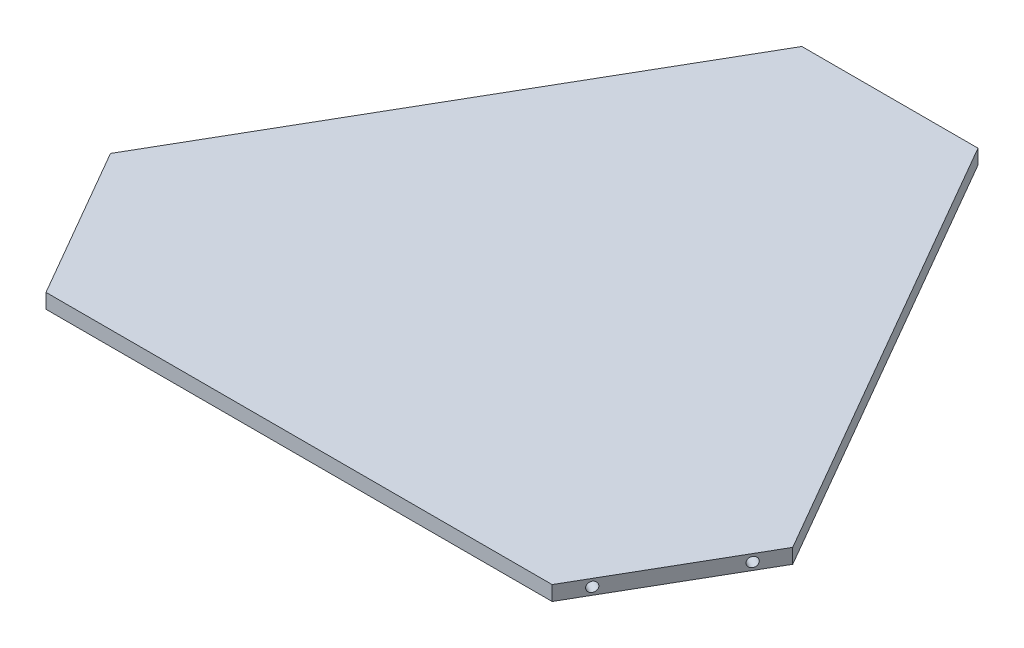
from build123d import *

# Parameters (mm, degrees)
BOSS_EXTRUDE1_DEPTH            = 6.35
M5X0_8_TAPPED_HOLE1_AT_2_COUNT = 2
M5X0_8_TAPPED_HOLE1_AT_2_PITCH = 50.8
CIRPATTERN1_COUNT              = 3


with BuildPart() as part:
    # Sketch1 → Boss-Extrude1 (new body)
    with BuildSketch(Plane(origin=(0, 0, 0), x_dir=(1, 0, 0), z_dir=(0, 1, 0))):
        Polygon((-147.591032992, -41.217632116), (-109.491032992, -107.208767884), (109.491032992, -107.208767884), (147.591032992, -41.217632116), (38.1, 148.4264), (-38.1, 148.4264), align=None)
    extrude(amount=BOSS_EXTRUDE1_DEPTH)

    # Sketch3 → M5x0.8 Tapped Hole1 (revolve, cut)
    with BuildSketch(Plane(origin=(115.841032992, 3.175, 96.210245256), x_dir=(0.5, 0, -0.866025404), z_dir=(0, 1, 0))):
        Polygon((0, 0), (0, 13.9618073), (2.1, 12.7), (2.1, 0), align=None)
    m5x0_8_tapped_hole1 = revolve(axis=Axis((121.340294306, 3.175, 99.385245256), (-0.866025404, 0, -0.5)), mode=Mode.SUBTRACT)

    # M5x0.8 Tapped Hole1 at 2: M5x0.8 Tapped Hole1 ×2
    with Locations(*[Vector(0.5, 0, -0.866025404) * (i * M5X0_8_TAPPED_HOLE1_AT_2_PITCH) for i in range(1, M5X0_8_TAPPED_HOLE1_AT_2_COUNT)]):
        add(m5x0_8_tapped_hole1, mode=Mode.SUBTRACT)

    # CirPattern1: M5x0.8 Tapped Hole1 ×3 about axis
    cirpattern1_axis = Axis((0, 6.6675, 0), (0, -1, 0))
    for i in range(1, CIRPATTERN1_COUNT):
        add(m5x0_8_tapped_hole1.rotate(cirpattern1_axis, i * 360 / CIRPATTERN1_COUNT), mode=Mode.SUBTRACT)

    # CirPattern1 copy 1 sketch → CirPattern1 copy 1 (revolve, cut)
    with BuildSketch(Plane(origin=(-115.841032992, 3.175, 96.210245256), x_dir=(0.5, 0, 0.866025404), z_dir=(0, 1, 0))):
        Polygon((0, 0), (0, 13.9618073), (2.1, 12.7), (2.1, 0), align=None)
    revolve(axis=Axis((-121.340294306, 3.175, 99.385245256), (0.866025404, 0, -0.5)), mode=Mode.SUBTRACT)

    # CirPattern1 copy 2 sketch → CirPattern1 copy 2 (revolve, cut)
    with BuildSketch(Plane(origin=(-25.4, 3.175, -148.4264), x_dir=(-1, 0, 0), z_dir=(0, 1, 0))):
        Polygon((0, 0), (0, 13.9618073), (2.1, 12.7), (2.1, 0), align=None)
    revolve(axis=Axis((-25.4, 3.175, -154.7764), (0, 0, 1)), mode=Mode.SUBTRACT)


solid = part.part
